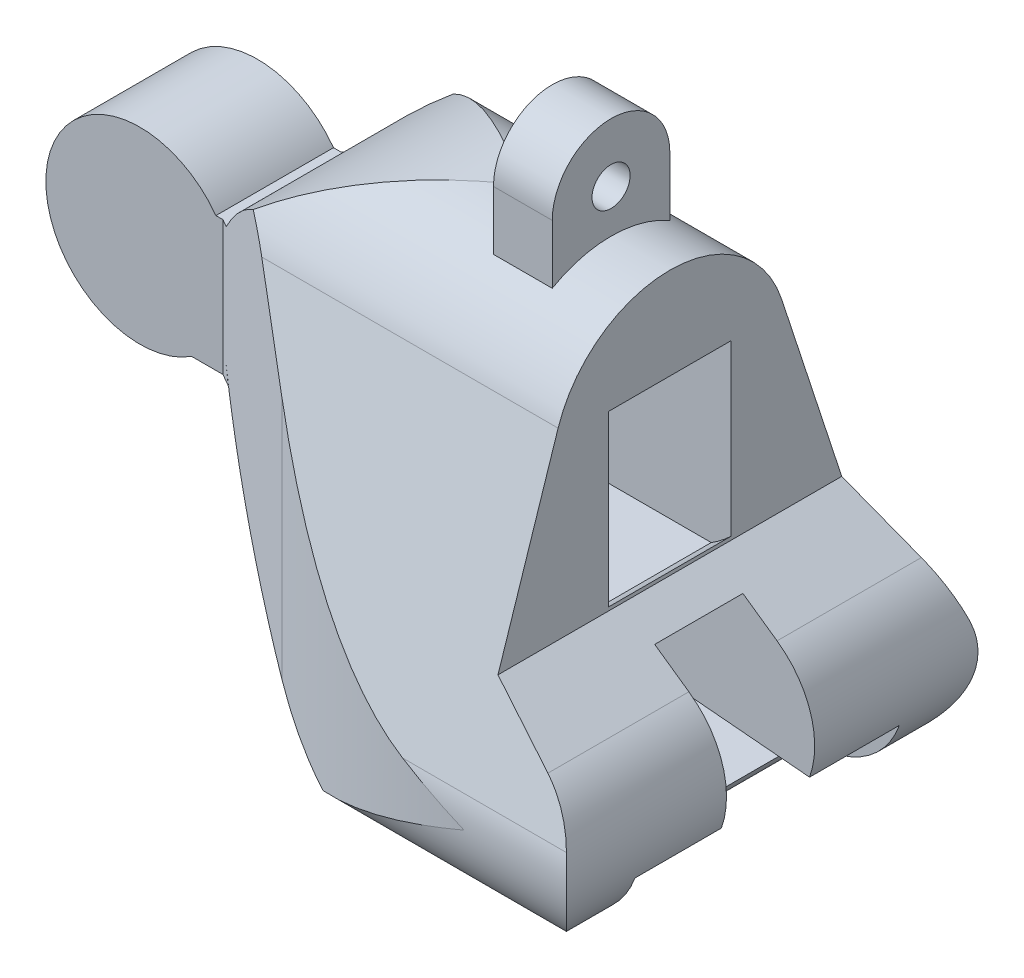
from build123d import *

# Parameters (mm, degrees)
BOSS_EXTRUDE1_DEPTH      = 6.35
BOSS_EXTRUDE2_START      = -7.9375
BOSS_EXTRUDE2_DEPTH      = 22.225
CUT_EXTRUDE1_DEPTH       = 51.557144521
CUT_EXTRUDE2_START       = -7.9375
CUT_EXTRUDE2_DEPTH       = 25.24
CUT_EXTRUDE7_DEPTH       = 10
CUT_EXTRUDE7_DEPTH_BACK  = 19.05
CUT_EXTRUDE10_DEPTH      = 10.16
CUT_EXTRUDE10_DEPTH_BACK = 17.78
CUT_EXTRUDE8_START       = 0.127
CUT_EXTRUDE8_DEPTH       = 6.604
BOSS_EXTRUDE3_START      = -3.175
BOSS_EXTRUDE3_DEPTH      = 3.175
SKETCH14_W               = 1.0287
SKETCH14_H               = 3.176
SKETCH15_W               = 4.7625
SKETCH15_H               = 4.7625
CUT_EXTRUDE15_DEPTH      = 8.703074479
CUT_EXTRUDE16_START      = -3.175
SKETCH16_W               = 4.7625
SKETCH16_H               = 4.7625
CUT_EXTRUDE16_DEPTH      = 32.52405251
SKETCH18_W               = 1.0287
SKETCH18_H               = 3.176
CUT_EXTRUDE17_DEPTH      = 4.7625
BOSS_EXTRUDE5_REACH      = 39.621
BOSS_EXTRUDE6_DEPTH      = 6.35
BOSS_EXTRUDE8_REACH      = 39.621
CUT_EXTRUDE19_DEPTH      = 10.31875
CUT_EXTRUDE19_DEPTH_BACK = 3.96875


with BuildPart() as part:
    # Sketch2 → Boss-Extrude1 (new body)
    with BuildSketch(Plane.XY):
        with BuildLine():
            Line((4.487320853, -2.38125), (4.487320853, 2.38125))
            ThreePointArc((4.487320853, 2.38125), (-5.08, 0), (4.487320853, -2.38125))
        make_face()
    extrude(amount=BOSS_EXTRUDE1_DEPTH)


with BuildPart() as body_2:
    # Sketch3 → Boss-Extrude2 (new body)
    with BuildSketch(Plane.XY.offset(BOSS_EXTRUDE2_START)):
        Polygon((4.487320853, 9.525), (25.442320853, 9.525), (25.442320853, -4.7625), (41.312615578, -15.875), (25.442320853, -15.875), (4.487320853, -15.875), align=None)
    extrude(amount=BOSS_EXTRUDE2_DEPTH)

    # Sketch4 → Cut-Extrude1 (cut, through all)
    with BuildSketch(Plane(origin=(0, 9.525, 0), x_dir=(1, 0, 0), z_dir=(0, 1, 0))):
        with BuildLine():
            Line((4.487320853, -6.35), (11.994161802, -10.684076643))
            ThreePointArc((11.994161802, -10.684076643), (18.481041485, -13.371030185), (25.442320853, -14.2875))
            Line((25.442320853, -14.2875), (4.487320853, -14.2875))
            Line((4.487320853, -14.2875), (4.487320853, -6.35))
        make_face()
        with BuildLine():
            Line((4.487320853, 0), (11.994161802, 4.334076643))
            ThreePointArc((11.994161802, 4.334076643), (18.481041485, 7.021030185), (25.442320853, 7.9375))
            Line((25.442320853, 7.9375), (4.487320853, 7.9375))
            Line((4.487320853, 7.9375), (4.487320853, 0))
        make_face()
    extrude(amount=-CUT_EXTRUDE1_DEPTH, mode=Mode.SUBTRACT)

    # Sketch5 → Cut-Extrude2 (cut)
    with BuildSketch(Plane.XY.offset(CUT_EXTRUDE2_START)):
        with BuildLine():
            Line((4.487320853, -15.875), (4.487320853, -2.38125))
            Line((4.487320853, -2.38125), (4.836453379, -3.34048373))
            ThreePointArc((4.836453379, -3.34048373), (11.810966692, -12.429846444), (22.737597804, -15.875))
            Line((22.737597804, -15.875), (4.487320853, -15.875))
        make_face()
        with BuildLine():
            Line((4.487320853, 2.38125), (4.487320853, 9.525))
            Line((4.487320853, 9.525), (17.504820853, 9.525))
            ThreePointArc((17.504820853, 9.525), (10.080393765, 7.621692137), (4.487320853, 2.38125))
        make_face()
        with BuildLine():
            Line((26.207895332, -15.875), (41.312615578, -15.875))
            Line((41.312615578, -15.875), (28.93955311, -7.211288389))
            ThreePointArc((28.93955311, -7.211288389), (30.74997231, -12.54461137), (26.207895332, -15.875))
        make_face()
    extrude(amount=CUT_EXTRUDE2_DEPTH, mode=Mode.SUBTRACT)

    # Sketch7 → Cut-Extrude7 (cut, two sides)
    with BuildSketch(Plane(origin=(25.442320853, 0, 0), x_dir=(0, 0, -1), z_dir=(1, 0, 0))) as cut_extrude7_sk:
        with BuildLine():
            ThreePointArc((-9.525, -15.875), (-12.892596049, -14.480096041), (-14.2875, -11.112499989))
            Line((-14.2875, -11.112499989), (-14.2875, -15.875))
            Line((-14.2875, -15.875), (-9.525, -15.875))
        make_face()
        with BuildLine():
            ThreePointArc((7.9375, -11.112499982), (6.542596052, -14.480096039), (3.175, -15.875))
            Line((3.175, -15.875), (7.9375, -15.875))
            Line((7.9375, -15.875), (7.9375, -11.112499982))
        make_face()
    extrude(amount=CUT_EXTRUDE7_DEPTH, mode=Mode.SUBTRACT)
    extrude(cut_extrude7_sk.sketch, amount=-CUT_EXTRUDE7_DEPTH_BACK, mode=Mode.SUBTRACT)

    # Sketch7_4 → Cut-Extrude10 (cut, two sides)
    with BuildSketch(Plane(origin=(25.442320853, 0, 0), x_dir=(0, 0, -1), z_dir=(1, 0, 0))) as cut_extrude10_sk:
        with BuildLine():
            ThreePointArc((-9.209570672, 5.151475854), (-6.901384194, 8.316649622), (-3.175, 9.525))
            Line((-3.175, 9.525), (-14.2875, 9.525))
            Line((-14.2875, 9.525), (-14.2875, -4.7625))
            Line((-14.2875, -4.7625), (-12.456650698, -4.7625))
            Line((-12.456650698, -4.7625), (-9.209570672, 5.151475854))
        make_face()
        with BuildLine():
            Line((6.106650698, -4.7625), (7.9375, -4.7625))
            Line((7.9375, -4.7625), (7.9375, 9.525))
            Line((7.9375, 9.525), (-3.175, 9.525))
            ThreePointArc((-3.175, 9.525), (0.551384194, 8.316649622), (2.859570672, 5.151475854))
            Line((2.859570672, 5.151475854), (6.106650698, -4.7625))
        make_face()
        with BuildLine():
            ThreePointArc((7.700928004, -9.630143109), (7.877985134, -10.361942155), (7.9375, -11.112499982))
            Line((7.9375, -11.112499982), (7.9375, -4.7625))
            Line((7.9375, -4.7625), (6.106650698, -4.7625))
            Line((6.106650698, -4.7625), (7.700928004, -9.630143109))
        make_face()
        with BuildLine():
            Line((-14.050928004, -9.630143109), (-12.456650698, -4.7625))
            Line((-12.456650698, -4.7625), (-14.2875, -4.7625))
            Line((-14.2875, -4.7625), (-14.2875, -11.112499989))
            ThreePointArc((-14.2875, -11.112499989), (-14.227985135, -10.361942158), (-14.050928004, -9.630143109))
        make_face()
    extrude(amount=CUT_EXTRUDE10_DEPTH, mode=Mode.SUBTRACT)
    extrude(cut_extrude10_sk.sketch, amount=-CUT_EXTRUDE10_DEPTH_BACK, mode=Mode.SUBTRACT)

    # Sketch8 → Cut-Extrude8 (cut)
    with BuildSketch(Plane.XY.offset(6.35).offset(CUT_EXTRUDE8_START)):
        with BuildLine():
            Line((25.442320853, -4.572), (25.442320853, 4.572))
            ThreePointArc((25.442320853, 4.572), (24.931170577, 5.014670211), (24.375846843, 5.400477249))
            Line((24.375846843, 5.400477249), (17.695324263, 5.400477249))
            Line((17.695324263, 5.400477249), (17.695324263, -5.400477249))
            Line((17.695324263, -5.400477249), (24.375846843, -5.400477249))
            ThreePointArc((24.375846843, -5.400477249), (24.931170577, -5.014670211), (25.442320853, -4.572))
        make_face()
    extrude(amount=-CUT_EXTRUDE8_DEPTH, mode=Mode.SUBTRACT)

    # Sketch12 → Boss-Extrude3 (add)
    with BuildSketch(Plane(origin=(25.442320853, 0, 0), x_dir=(0, 0, -1), z_dir=(1, 0, 0)).offset(BOSS_EXTRUDE3_START)):
        with BuildLine():
            Line((-6.35, 8.674261314), (0, 8.674261314))
            Line((0, 8.674261314), (0, 11.849261314))
            ThreePointArc((0, 11.849261314), (-3.175, 15.024261314), (-6.35, 11.849261314))
            Line((-6.35, 11.849261314), (-6.35, 8.674261314))
        make_face()
    extrude(amount=-BOSS_EXTRUDE3_DEPTH)

    # Sketch14 → 1 Clearance Hole1 (revolve, cut)
    with BuildSketch(Plane(origin=(22.267320853, 11.849261314, 3.175), x_dir=(0, 0, -1), z_dir=(0, 1, 0))):
        with Locations((0.51435, 1.588)):
            Rectangle(SKETCH14_W, SKETCH14_H)
    revolve(axis=Axis((28.617320853, 11.849261314, 3.175), (-1, 0, 0)), mode=Mode.SUBTRACT)

    # Sketch15 → Cut-Extrude15 (cut)
    with BuildSketch(Plane(origin=(30.970395332, 0, 0), x_dir=(0, 0, -1), z_dir=(1, 0, 0))):
        with Locations((-3.262930867, -9.592538389)):
            Rectangle(SKETCH15_W, SKETCH15_H)
    extrude(amount=-CUT_EXTRUDE15_DEPTH, mode=Mode.SUBTRACT)

    # Sketch16 → Cut-Extrude16 (cut, through all)
    with BuildSketch(Plane(origin=(22.267320853, 0, 0), x_dir=(0, 0, -1), z_dir=(1, 0, 0)).offset(CUT_EXTRUDE16_START)):
        with Locations((-3.262930867, -9.592538389)):
            Rectangle(SKETCH16_W, SKETCH16_H)
    extrude(amount=-CUT_EXTRUDE16_DEPTH, mode=Mode.SUBTRACT)

    # Sketch18 → 1 Clearance Hole2 (revolve, cut)
    with BuildSketch(Plane(origin=(22.267320853, -9.592538389, 3.262930867), x_dir=(0, 0, -1), z_dir=(0, 1, 0))):
        with Locations((0.51435, 1.588)):
            Rectangle(SKETCH18_W, SKETCH18_H)
    revolve(axis=Axis((28.617320853, -9.592538389, 3.262930867), (-1, 0, 0)), mode=Mode.SUBTRACT)

    # Sketch19 → Cut-Extrude17 (cut)
    with BuildSketch(Plane.XY.offset(0.881680867)):
        with BuildLine():
            Line((19.092320853, -11.973788389), (13.48400503, -13.476532085))
            ThreePointArc((13.48400503, -13.476532085), (9.265001461, -10.293171657), (6.083027043, -6.07312266))
            Line((6.083027043, -6.07312266), (19.092320853, -7.211288389))
            Line((19.092320853, -7.211288389), (19.092320853, -11.973788389))
        make_face()
        with BuildLine():
            Line((22.267320853, -7.211288389), (27.092931392, -5.918269942))
            Line((27.092931392, -5.918269942), (28.93955311, -7.211288389))
            ThreePointArc((28.93955311, -7.211288389), (30.745098667, -9.665022145), (30.694106103, -12.711036568))
            Line((30.694106103, -12.711036568), (22.267320853, -11.973788389))
            Line((22.267320853, -11.973788389), (22.267320853, -7.211288389))
        make_face()
    extrude(amount=CUT_EXTRUDE17_DEPTH, mode=Mode.SUBTRACT)

    # Boss-Extrude5: up to this face of the body (flat: up to its plane)
    boss_extrude5_end = Plane(body_2.part.faces().sort_by_distance((8.620061627, -2.410659079, -2.386038999))[0])
    # Sketch21 → Boss-Extrude5 (add, up to the picked face)
    with BuildSketch(Plane(origin=(0, 0, 0), x_dir=(-1, 0, 0), z_dir=(0, 0, -1)), mode=Mode.PRIVATE) as boss_extrude5_sk1:
        with BuildLine():
            Line((-4.487320853, 2.38125), (-4.487320853, 2.993520531))
            Line((-4.487320853, 2.993520531), (-4.898044681, 2.993520531))
            ThreePointArc((-4.898044681, 2.993520531), (-4.689025867, 2.689838391), (-4.487320853, 2.38125))
        make_face()
    boss_extrude5_tool1 = split(extrude(boss_extrude5_sk1.sketch, amount=BOSS_EXTRUDE5_REACH, mode=Mode.PRIVATE), bisect_by=boss_extrude5_end, keep=Keep.BOTH, mode=Mode.PRIVATE)
    # Sketch21 → Boss-Extrude5 (add, up to the picked face)
    with BuildSketch(Plane(origin=(0, 0, 0), x_dir=(-1, 0, 0), z_dir=(0, 0, -1)), mode=Mode.PRIVATE) as boss_extrude5_sk2:
        Polygon((-4.487320853, -2.38125), (-5.166825139, -4.248172683), (-4.487320853, -4.248172683), align=None)
    boss_extrude5_tool2 = split(extrude(boss_extrude5_sk2.sketch, amount=BOSS_EXTRUDE5_REACH, mode=Mode.PRIVATE), bisect_by=boss_extrude5_end, keep=Keep.BOTH, mode=Mode.PRIVATE)

    add(part.part)  # Boss-Extrude5 merges part
    add(boss_extrude5_tool1.solids().sort_by(Axis((4.623055, 2.791201, 0), (0, 0, -1)))[0])
    add(boss_extrude5_tool2.solids().sort_by(Axis((4.713822, -3.625865, 0), (0, 0, -1)))[0])

    # Sketch21_3 → Boss-Extrude6 (add)
    with BuildSketch(Plane(origin=(0, 0, 0), x_dir=(-1, 0, 0), z_dir=(0, 0, -1))):
        with BuildLine():
            Line((-5.166825139, -4.248172683), (-4.487320853, -2.38125))
            ThreePointArc((-4.487320853, -2.38125), (-3.754344697, -3.42217707), (-2.785575139, -4.248172683))
            Line((-2.785575139, -4.248172683), (-5.166825139, -4.248172683))
        make_face()
        with BuildLine():
            Line((-4.104294681, 2.993520531), (-4.898044681, 2.993520531))
            ThreePointArc((-4.898044681, 2.993520531), (-4.689025867, 2.689838391), (-4.487320853, 2.38125))
            ThreePointArc((-4.487320853, 2.38125), (-4.306702123, 2.694200592), (-4.104294681, 2.993520531))
        make_face()
    extrude(amount=-BOSS_EXTRUDE6_DEPTH)

    # Boss-Extrude8: up to this face of the body (flat: up to its plane)
    boss_extrude8_end = Plane(body_2.part.faces().sort_by_distance((8.620061627, -2.410659079, 8.736038999))[0])
    # Sketch22 → Boss-Extrude8 (add, up to the picked face)
    with BuildSketch(Plane.XY.offset(6.35), mode=Mode.PRIVATE) as boss_extrude8_sk1:
        Polygon((4.487320853, 2.38125), (4.501169681, 2.993520531), (4.898044681, 2.993520531), align=None)
    boss_extrude8_tool1 = split(extrude(boss_extrude8_sk1.sketch, amount=BOSS_EXTRUDE8_REACH, mode=Mode.PRIVATE), bisect_by=boss_extrude8_end, keep=Keep.BOTH, mode=Mode.PRIVATE)
    # Sketch22 → Boss-Extrude8 (add, up to the picked face)
    with BuildSketch(Plane.XY.offset(6.35), mode=Mode.PRIVATE) as boss_extrude8_sk2:
        Polygon((4.487320853, -2.38125), (4.487320853, -4.248172683), (5.166825139, -4.248172683), align=None)
    boss_extrude8_tool2 = split(extrude(boss_extrude8_sk2.sketch, amount=BOSS_EXTRUDE8_REACH, mode=Mode.PRIVATE), bisect_by=boss_extrude8_end, keep=Keep.BOTH, mode=Mode.PRIVATE)
    add(boss_extrude8_tool1.solids().sort_by(Axis((4.628845, 2.78943, 6.35), (0, 0, 1)))[0])
    add(boss_extrude8_tool2.solids().sort_by(Axis((4.713822, -3.625865, 6.35), (0, 0, 1)))[0])

    # Sketch28 → Cut-Extrude19 (cut, two sides)
    with BuildSketch(Plane.XY) as cut_extrude19_sk:
        with BuildLine():
            Line((29.030898019, -12.565524716), (30.694106103, -12.711036568))
            ThreePointArc((30.694106103, -12.711036568), (28.952742854, -15.004442745), (26.207895332, -15.875))
            Line((26.207895332, -15.875), (22.737597804, -15.875))
            ThreePointArc((22.737597804, -15.875), (19.409236601, -15.581985677), (16.183264637, -14.711956609))
            ThreePointArc((16.183264637, -14.711956609), (14.809533786, -14.146902347), (13.48400503, -13.476532085))
            Line((13.48400503, -13.476532085), (15.808154767, -12.85377804))
            ThreePointArc((15.808154767, -12.85377804), (16.266196274, -13.044120459), (16.729459067, -13.221376891))
            ThreePointArc((16.729459067, -13.221376891), (19.686600035, -14.018903538), (22.737597804, -14.2875))
            Line((22.737597804, -14.2875), (26.207895332, -14.2875))
            ThreePointArc((26.207895332, -14.2875), (27.861266362, -13.823033017), (29.030898019, -12.565524716))
        make_face()
    extrude(amount=CUT_EXTRUDE19_DEPTH, mode=Mode.SUBTRACT)
    extrude(cut_extrude19_sk.sketch, amount=-CUT_EXTRUDE19_DEPTH_BACK, mode=Mode.SUBTRACT)


solid = body_2.part
